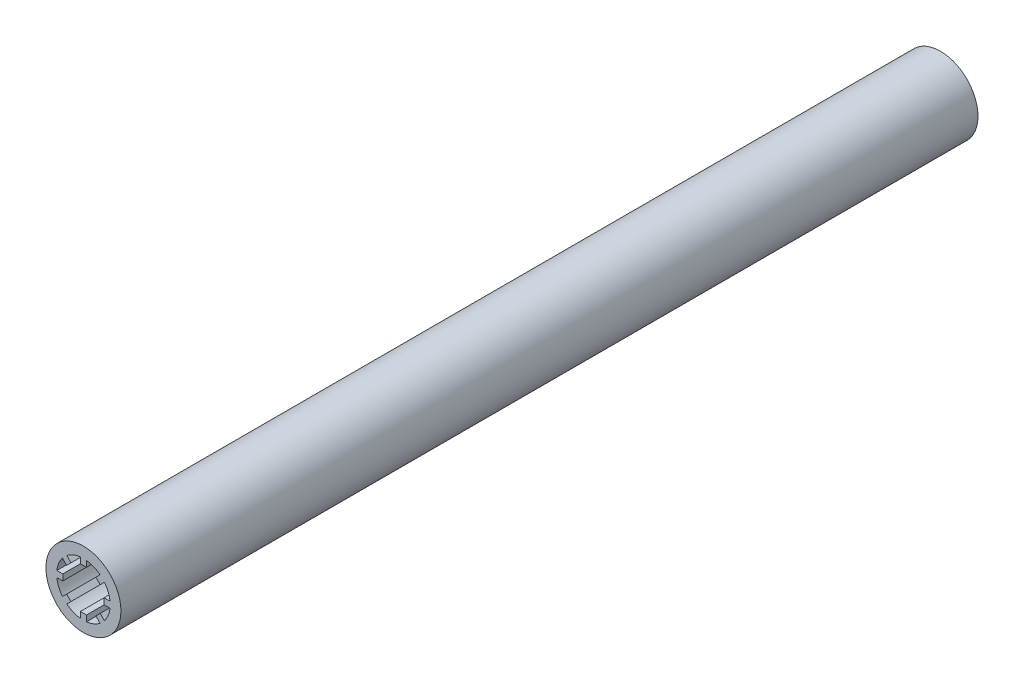
from build123d import *

# Parameters (mm, degrees)
SKETCH1_R           = 12.25
BOSS_EXTRUDE1_DEPTH = 280
CUT_EXTRUDE1_DEPTH  = 20


with BuildPart() as part:
    # Sketch1 → Boss-Extrude1 (new body)
    with BuildSketch(Plane.XY):
        Circle(SKETCH1_R)
    extrude(amount=BOSS_EXTRUDE1_DEPTH)

    # Sketch2 → Cut-Extrude1 (cut)
    with BuildSketch(Plane.XY.offset(280)):
        with BuildLine():
            Line((1, 6.75), (-1, 6.75))
            Line((-1, 6.75), (-1, 8.692669325))
            ThreePointArc((-1, 8.692669325), (-3.348480033, 8.083945909), (-5.439538645, 6.853752208))
            Line((-5.439538645, 6.853752208), (-4.065863992, 5.480077554))
            Line((-4.065863992, 5.480077554), (-5.480077554, 4.065863992))
            Line((-5.480077554, 4.065863992), (-6.853752208, 5.439538645))
            ThreePointArc((-6.853752208, 5.439538645), (-8.083945909, 3.348480033), (-8.692669325, 1))
            Line((-8.692669325, 1), (-6.75, 1))
            Line((-6.75, 1), (-6.75, -1))
            Line((-6.75, -1), (-8.692669325, -1))
            ThreePointArc((-8.692669325, -1), (-8.083945909, -3.348480033), (-6.853752208, -5.439538645))
            Line((-6.853752208, -5.439538645), (-5.480077554, -4.065863992))
            Line((-5.480077554, -4.065863992), (-4.065863992, -5.480077554))
            Line((-4.065863992, -5.480077554), (-5.439538645, -6.853752208))
            ThreePointArc((-5.439538645, -6.853752208), (-3.348480033, -8.083945909), (-1, -8.692669325))
            Line((-1, -8.692669325), (-1, -6.75))
            Line((-1, -6.75), (1, -6.75))
            Line((1, -6.75), (1, -8.692669325))
            ThreePointArc((1, -8.692669325), (3.348480033, -8.083945909), (5.439538645, -6.853752208))
            Line((5.439538645, -6.853752208), (4.065863992, -5.480077554))
            Line((4.065863992, -5.480077554), (5.480077554, -4.065863992))
            Line((5.480077554, -4.065863992), (6.853752208, -5.439538645))
            ThreePointArc((6.853752208, -5.439538645), (8.083945909, -3.348480033), (8.692669325, -1))
            Line((8.692669325, -1), (6.75, -1))
            Line((6.75, -1), (6.75, 1))
            Line((6.75, 1), (8.692669325, 1))
            ThreePointArc((8.692669325, 1), (8.083945909, 3.348480033), (6.853752208, 5.439538645))
            Line((6.853752208, 5.439538645), (5.480077554, 4.065863992))
            Line((5.480077554, 4.065863992), (4.065863992, 5.480077554))
            Line((4.065863992, 5.480077554), (5.439538645, 6.853752208))
            ThreePointArc((5.439538645, 6.853752208), (3.348480033, 8.083945909), (1, 8.692669325))
            Line((1, 8.692669325), (1, 6.75))
        make_face()
    extrude(amount=-CUT_EXTRUDE1_DEPTH, mode=Mode.SUBTRACT)


solid = part.part
